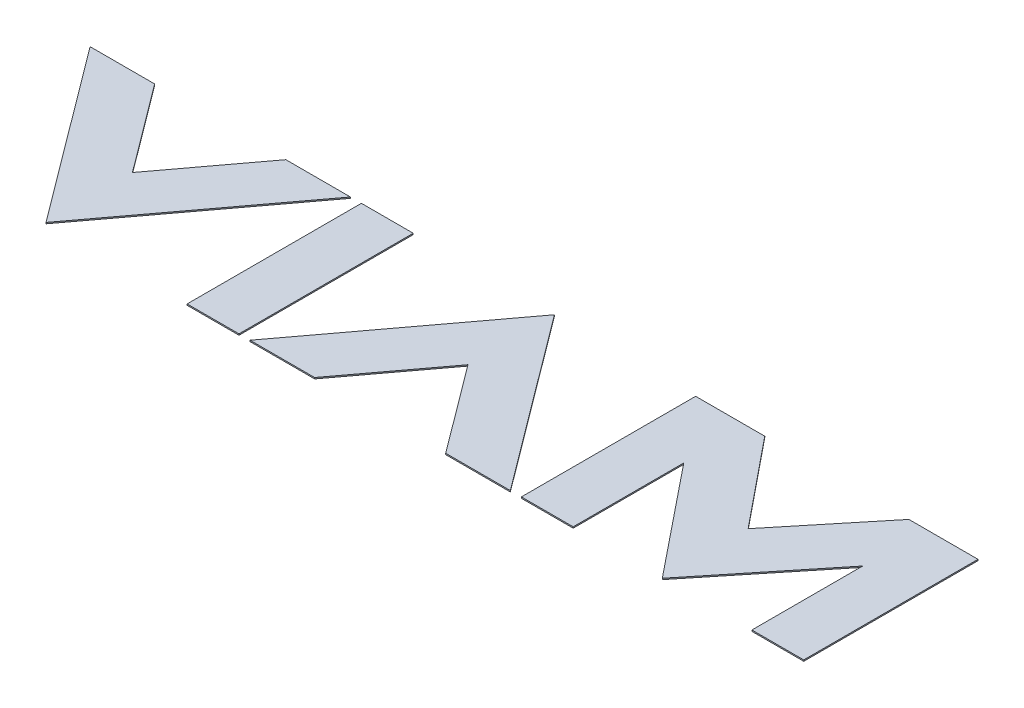
from build123d import *

# Parameters (mm, degrees)
SKETCH2_W             = 4.1713404
SKETCH2_H             = 14.01875022
BOSS_EXTRUDE3_DEPTH   = 0.1
BOSS_EXTRUDE3_2_DEPTH = 0.1
BOSS_EXTRUDE3_3_DEPTH = 0.1
BOSS_EXTRUDE3_4_DEPTH = 0.1


with BuildPart() as part:
    # Sketch2 → Boss-Extrude3 (new body)
    with BuildSketch(Plane(origin=(-16.778352461, 0, 2.915945943), x_dir=(1, 0, 0), z_dir=(0, 1, 0))):
        with Locations((4.648707026, 3.190600736)):
            Rectangle(SKETCH2_W, SKETCH2_H)
    extrude(amount=BOSS_EXTRUDE3_DEPTH)


with BuildPart() as body_2:
    # Sketch2 → Boss-Extrude3 2 (new body)
    with BuildSketch(Plane(origin=(-16.778352461, 0, 2.915945943), x_dir=(1, 0, 0), z_dir=(0, 1, 0))):
        Polygon((46.612047026, 10.199975846), (40.791205226, 3.085181846), (35.015931026, 10.199975846), (29.455540826, 10.199975846), (29.455540826, -3.818774374), (33.622690226, -3.818774374), (33.622690226, 5.077811846), (40.791205226, -3.818774374), (48.001096826, 5.098538246), (48.001096826, -3.818774374), (52.172437226, -3.818774374), (52.172437226, 10.199975846), align=None)
    extrude(amount=BOSS_EXTRUDE3_2_DEPTH)


with BuildPart() as body_3:
    # Sketch2 → Boss-Extrude3 3 (new body)
    with BuildSketch(Plane(origin=(-16.778352461, 0, 2.915945943), x_dir=(1, 0, 0), z_dir=(0, 1, 0))):
        Polygon((-3.518256574, 10.199975846), (-8.793353974, 3.134788046), (-14.068474234, 10.199975846), (-19.265062774, 10.199975846), (-8.793353974, -3.818774374), (1.678431026, 10.199975846), align=None)
    extrude(amount=BOSS_EXTRUDE3_3_DEPTH)


with BuildPart() as body_4:
    # Sketch2 → Boss-Extrude3 4 (new body)
    with BuildSketch(Plane(origin=(-16.778352461, 0, 2.915945943), x_dir=(1, 0, 0), z_dir=(0, 1, 0))):
        Polygon((18.094959026, 10.199975846), (7.623250226, -3.818774374), (12.819785426, -3.818774374), (18.094959026, 3.242306246), (23.370132626, -3.822904414), (28.566667826, -3.822904414), align=None)
    extrude(amount=BOSS_EXTRUDE3_4_DEPTH)


solid = Compound([part.part, body_2.part, body_3.part, body_4.part])
